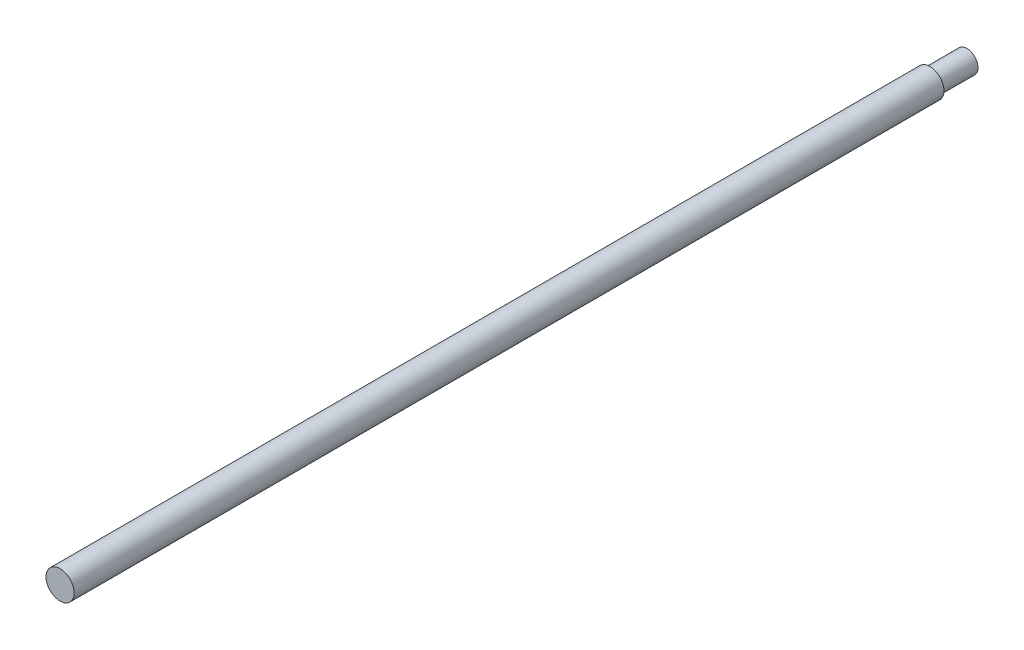
from build123d import *

# Parameters (mm, degrees)
SKETCH1_R           = 3.8
BOSS_EXTRUDE1_DEPTH = 245
SKETCH2_OUTSIDE_W   = 58.648
SKETCH2_OUTSIDE_H   = 58.648
SKETCH2_OUTSIDE_R   = 3
CUT_EXTRUDE1_DEPTH  = 10


with BuildPart() as part:
    # Sketch1 → Boss-Extrude1 (new body)
    with BuildSketch(Plane.XY):
        Circle(SKETCH1_R)
    extrude(amount=BOSS_EXTRUDE1_DEPTH)

    # Sketch2 outside → Cut-Extrude1 (cut)
    with BuildSketch(Plane(origin=(0, 0, 0), x_dir=(-1, 0, 0), z_dir=(0, 0, -1))):
        Rectangle(SKETCH2_OUTSIDE_W, SKETCH2_OUTSIDE_H)
        Circle(SKETCH2_OUTSIDE_R, mode=Mode.SUBTRACT)
    extrude(amount=-CUT_EXTRUDE1_DEPTH, mode=Mode.SUBTRACT)


solid = part.part
